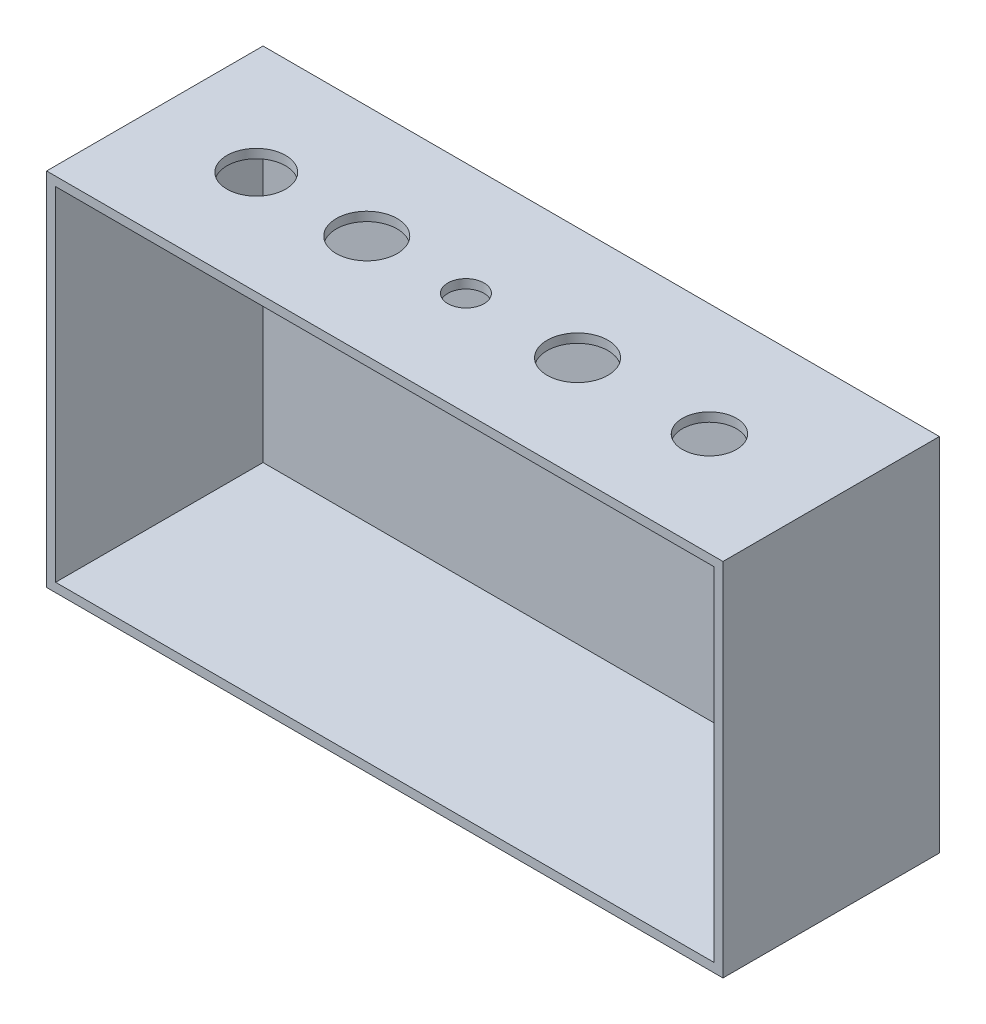
from build123d import *

# Parameters (mm, degrees)
SKETCH1_W          = 150
SKETCH1_H          = 50
EXTRUDE5_DEPTH     = 80
SHELL1_T           = 2
EXTRUDE6_REACH     = 82
SKETCH8_R          = 6.5
SKETCH8_R_2        = 6.75
SKETCH8_R_3        = 4
SKETCH8_R_4        = 6
SKETCH12_W         = 2
SKETCH12_H         = 80
CUT_EXTRUDE1_DEPTH = 200


with BuildPart() as part:
    # Sketch1 → Extrude5 (new body)
    with BuildSketch(Plane(origin=(0, 0, 0), x_dir=(1, 0, 0), z_dir=(0, 1, 0))):
        with Locations((75, 25)):
            Rectangle(SKETCH1_W, SKETCH1_H)
    extrude(amount=-EXTRUDE5_DEPTH)

    # Shell1 (no face opened: a closed hollow body)
    add(offset(amount=-SHELL1_T, mode=Mode.PRIVATE), mode=Mode.SUBTRACT)

    # Sketch8 → Extrude6 (cut, up to next)
    with BuildSketch(Plane(origin=(0, 0, 0), x_dir=(1, 0, 0), z_dir=(0, 1, 0)), mode=Mode.PRIVATE) as extrude6_sk1:
        with Locations(Location((23.5, 25, 0), (0, 0, 270))):  # turned: the seam where the file's is
            Circle(SKETCH8_R)
    extrude6_tool1 = extrude(extrude6_sk1.sketch, amount=-EXTRUDE6_REACH, mode=Mode.PRIVATE) & part.part
    add(extrude6_tool1.solids().sort_by_distance((23.5, 0, -25))[0], mode=Mode.SUBTRACT)
    # Sketch8 → Extrude6 (cut, up to next)
    with BuildSketch(Plane(origin=(0, 0, 0), x_dir=(1, 0, 0), z_dir=(0, 1, 0)), mode=Mode.PRIVATE) as extrude6_sk2:
        with Locations(Location((48, 25, 0), (0, 0, 270))):  # turned: the seam where the file's is
            Circle(SKETCH8_R_2)
    extrude6_tool2 = extrude(extrude6_sk2.sketch, amount=-EXTRUDE6_REACH, mode=Mode.PRIVATE) & part.part
    add(extrude6_tool2.solids().sort_by_distance((48, 0, -25))[0], mode=Mode.SUBTRACT)
    # Sketch8 → Extrude6 (cut, up to next)
    with BuildSketch(Plane(origin=(0, 0, 0), x_dir=(1, 0, 0), z_dir=(0, 1, 0)), mode=Mode.PRIVATE) as extrude6_sk3:
        with Locations(Location((70, 25, 0), (0, 0, 270))):  # turned: the seam where the file's is
            Circle(SKETCH8_R_3)
    extrude6_tool3 = extrude(extrude6_sk3.sketch, amount=-EXTRUDE6_REACH, mode=Mode.PRIVATE) & part.part
    add(extrude6_tool3.solids().sort_by_distance((70, 0, -25))[0], mode=Mode.SUBTRACT)
    # Sketch8 → Extrude6 (cut, up to next)
    with BuildSketch(Plane(origin=(0, 0, 0), x_dir=(1, 0, 0), z_dir=(0, 1, 0)), mode=Mode.PRIVATE) as extrude6_sk4:
        with Locations(Location((94.75, 25, 0), (0, 0, 270))):  # turned: the seam where the file's is
            Circle(SKETCH8_R_2)
    extrude6_tool4 = extrude(extrude6_sk4.sketch, amount=-EXTRUDE6_REACH, mode=Mode.PRIVATE) & part.part
    add(extrude6_tool4.solids().sort_by_distance((94.75, 0, -25))[0], mode=Mode.SUBTRACT)
    # Sketch8 → Extrude6 (cut, up to next)
    with BuildSketch(Plane(origin=(0, 0, 0), x_dir=(1, 0, 0), z_dir=(0, 1, 0)), mode=Mode.PRIVATE) as extrude6_sk5:
        with Locations(Location((124, 25, 0), (0, 0, 270))):  # turned: the seam where the file's is
            Circle(SKETCH8_R_4)
    extrude6_tool5 = extrude(extrude6_sk5.sketch, amount=-EXTRUDE6_REACH, mode=Mode.PRIVATE) & part.part
    add(extrude6_tool5.solids().sort_by_distance((124, 0, -25))[0], mode=Mode.SUBTRACT)

    # Sketch12 → Cut-Extrude1 (cut)
    with BuildSketch(Plane.ZY):
        with Locations((-1, -40)):
            Rectangle(SKETCH12_W, SKETCH12_H)
    extrude(amount=-CUT_EXTRUDE1_DEPTH, mode=Mode.SUBTRACT)


solid = part.part
